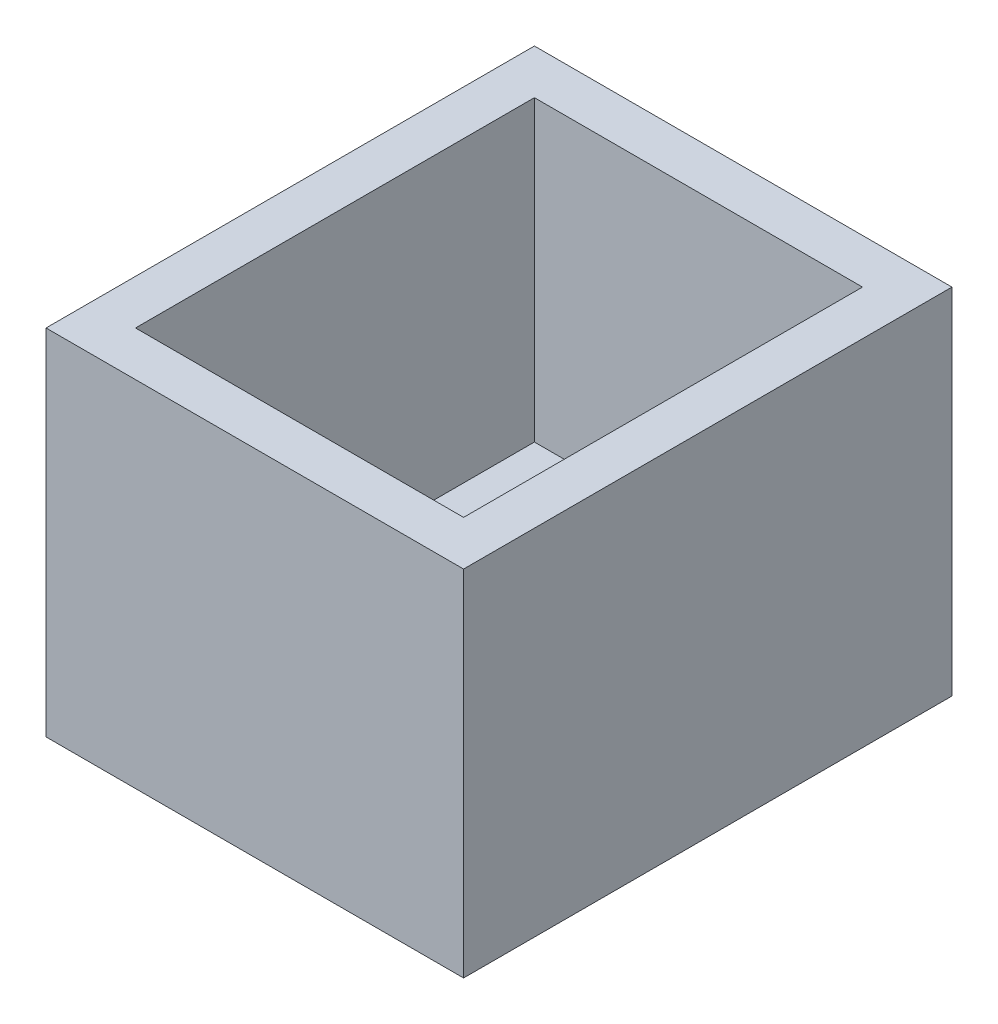
from build123d import *

# Parameters (mm, degrees)
SKETCH1_W           = 22
SKETCH1_H           = 26.75
SKETCH1_W_2         = 16
SKETCH1_H_2         = 20.75
BOSS_EXTRUDE2_DEPTH = 3.75
BOSS_EXTRUDE3_DEPTH = 1.875
SKETCH3_W           = 22
SKETCH3_H           = 3.75
BOSS_EXTRUDE4_DEPTH = 3
SKETCH4_W           = 29.75
SKETCH4_H           = 3.75
BOSS_EXTRUDE5_DEPTH = 3
SKETCH5_W           = 25
SKETCH5_H           = 3.75
BOSS_EXTRUDE6_DEPTH = 3
SKETCH6_W           = 32.75
SKETCH6_H           = 3.75
BOSS_EXTRUDE7_DEPTH = 3
SKETCH7_W           = 28
SKETCH7_H           = 32.75
SKETCH7_W_2         = 22
SKETCH7_H_2         = 26.75
BOSS_EXTRUDE8_DEPTH = 20


with BuildPart() as part:
    # Sketch1 → Boss-Extrude2 (new body)
    with BuildSketch(Plane(origin=(0, 0, 0), x_dir=(1, 0, 0), z_dir=(0, 1, 0))):
        with Locations((-47.484558715, -14.904779002)):
            Rectangle(SKETCH1_W, SKETCH1_H)
        with Locations((-47.484558715, -14.904779002)):
            Rectangle(SKETCH1_W_2, SKETCH1_H_2, mode=Mode.SUBTRACT)
    extrude(amount=BOSS_EXTRUDE2_DEPTH)

    # Sketch2 → Boss-Extrude3 (add)
    with BuildSketch(Plane(origin=(0, 3.75, 0), x_dir=(1, 0, 0), z_dir=(0, 1, 0))):
        Polygon((-50.984558715, -25.279779002), (-55.484558715, -25.279779002), (-55.484558715, -4.529779002), (-50.984558715, -4.529779002), (-50.984558715, -5.779779002), (-54.234558715, -5.779779002), (-54.234558715, -24.029779002), (-50.984558715, -24.029779002), align=None)
        Polygon((-43.984558715, -4.529779002), (-39.484558715, -4.529779002), (-39.484558715, -25.279779002), (-43.984558715, -25.279779002), (-43.984558715, -24.029779002), (-40.734558715, -24.029779002), (-40.734558715, -5.779779002), (-43.984558715, -5.779779002), align=None)
    extrude(amount=-BOSS_EXTRUDE3_DEPTH)

    # Sketch3 → Boss-Extrude4 (add)
    with BuildSketch(Plane(origin=(0, 0, 1.529779002), x_dir=(-1, 0, 0), z_dir=(0, 0, -1))):
        with Locations((47.484558715, 1.875)):
            Rectangle(SKETCH3_W, SKETCH3_H)
    extrude(amount=BOSS_EXTRUDE4_DEPTH)

    # Sketch4 → Boss-Extrude5 (add)
    with BuildSketch(Plane.ZY.offset(58.484558715)):
        with Locations((13.404779002, 1.875)):
            Rectangle(SKETCH4_W, SKETCH4_H)
    extrude(amount=BOSS_EXTRUDE5_DEPTH)

    # Sketch5 → Boss-Extrude6 (add)
    with BuildSketch(Plane.XY.offset(28.279779002)):
        with Locations((-48.984558715, 1.875)):
            Rectangle(SKETCH5_W, SKETCH5_H)
    extrude(amount=BOSS_EXTRUDE6_DEPTH)

    # Sketch6 → Boss-Extrude7 (add)
    with BuildSketch(Plane(origin=(-36.484558715, 0, 0), x_dir=(0, 0, -1), z_dir=(1, 0, 0))):
        with Locations((-14.904779002, 1.875)):
            Rectangle(SKETCH6_W, SKETCH6_H)
    extrude(amount=BOSS_EXTRUDE7_DEPTH)

    # Sketch7 → Boss-Extrude8 (add)
    with BuildSketch(Plane(origin=(0, 3.75, 0), x_dir=(1, 0, 0), z_dir=(0, 1, 0))):
        with Locations((-47.484558715, -14.904779002)):
            Rectangle(SKETCH7_W, SKETCH7_H)
        with Locations((-47.484558715, -14.904779002)):
            Rectangle(SKETCH7_W_2, SKETCH7_H_2, mode=Mode.SUBTRACT)
    extrude(amount=BOSS_EXTRUDE8_DEPTH)


solid = part.part
